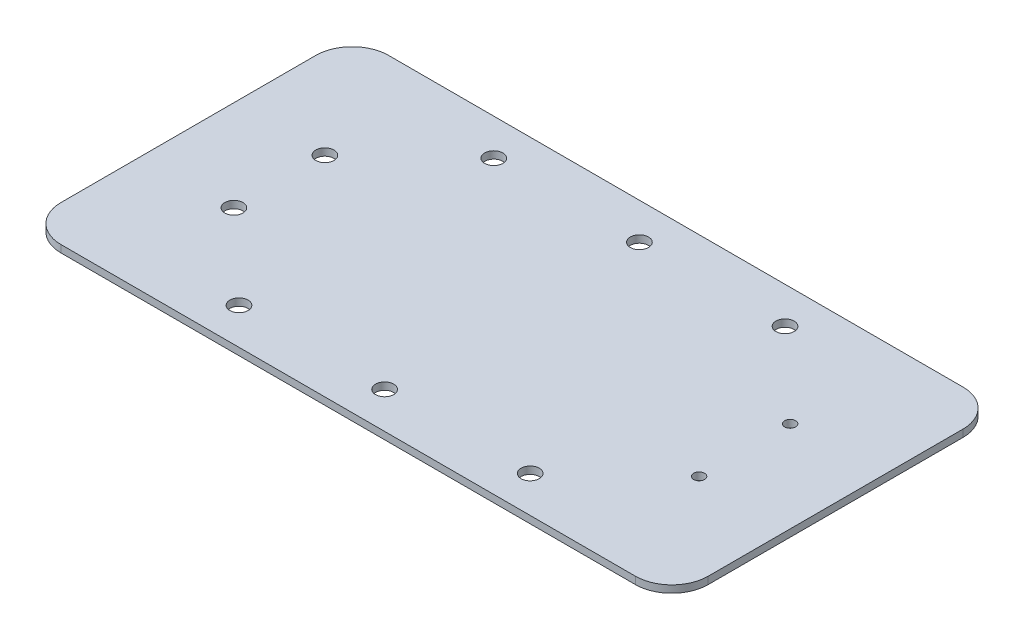
from build123d import *

# Parameters (mm, degrees)
SKETCH1_W           = 177.8
SKETCH1_H           = 90
SKETCH1_R           = 2.5
BOSS_EXTRUDE1_DEPTH = 2
FILLET1_R           = 10
SKETCH2_R           = 2.5
SKETCH2_R_2         = 1.5
CUT_EXTRUDE1_DEPTH  = 2


with BuildPart() as part:
    # Sketch1 → Boss-Extrude1 (new body)
    with BuildSketch(Plane(origin=(0, 0, 0), x_dir=(1, 0, 0), z_dir=(0, 1, 0))):
        Rectangle(SKETCH1_W, SKETCH1_H)
        with Locations((0, 35)):
            Circle(SKETCH1_R, mode=Mode.SUBTRACT)
        with Locations((0, -35)):
            Circle(SKETCH1_R, mode=Mode.SUBTRACT)
        with Locations((40, 35)):
            Circle(SKETCH1_R, mode=Mode.SUBTRACT)
        with Locations((40, -35)):
            Circle(SKETCH1_R, mode=Mode.SUBTRACT)
        with Locations((-40, 35)):
            Circle(SKETCH1_R, mode=Mode.SUBTRACT)
        with Locations((-40, -35)):
            Circle(SKETCH1_R, mode=Mode.SUBTRACT)
    extrude(amount=BOSS_EXTRUDE1_DEPTH)

    # Fillet1
    fillet1_edges = [part.edges().sort_by_distance(p)[0] for p in [
        (-88.9, 1, 45),
        (-88.9, 1, -45),
        (88.9, 1, -45),
        (88.9, 1, 45),
    ]]
    fillet(fillet1_edges, radius=FILLET1_R)

    # Sketch2 → Cut-Extrude1 (cut)
    with BuildSketch(Plane.XZ):
        with Locations((-63.9, 12.5)):
            Circle(SKETCH2_R)
        with Locations((-63.9, -12.5)):
            Circle(SKETCH2_R)
        with Locations((63.9, 12.5)):
            Circle(SKETCH2_R_2)
        with Locations((63.9, -12.5)):
            Circle(SKETCH2_R_2)
    extrude(amount=-CUT_EXTRUDE1_DEPTH, mode=Mode.SUBTRACT)


solid = part.part
